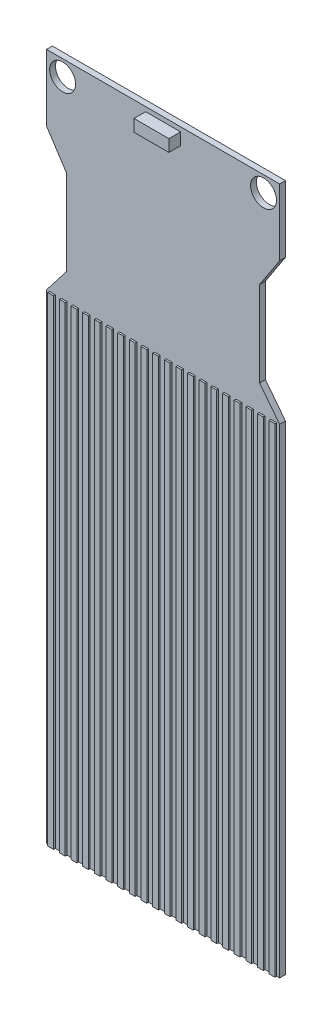
from build123d import *

# Parameters (mm, degrees)
SKETCH2_R           = 1.112004448
BOSS_EXTRUDE1_DEPTH = 0.5
SKETCH3_W           = 0.5
SKETCH3_H           = 41.135021261
BOSS_EXTRUDE2_DEPTH = 0.15
SKETCH4_W           = 1.5
SKETCH4_H           = 1.027696227
BOSS_EXTRUDE3_DEPTH = 1


with BuildPart() as part:
    # Sketch2 → Boss-Extrude1 (new body)
    with BuildSketch(Plane.XY):
        Polygon((-10, 13.571131009), (10, 13.571131009), (10, 54.708363732), (8.281546087, 56.925194639), (8.281546087, 64.240363418), (10, 66.862498938), (10, 72.571131009), (-10, 72.571131009), (-10, 66.862498938), (-8.281546087, 64.240363418), (-8.281546087, 56.925194639), (-10, 54.708363732), align=None)
        with Locations((8.618613348, 71.214744162)):
            Circle(SKETCH2_R, mode=Mode.SUBTRACT)
        with Locations((-8.618613348, 71.214744162)):
            Circle(SKETCH2_R, mode=Mode.SUBTRACT)
    extrude(amount=BOSS_EXTRUDE1_DEPTH)

    # Sketch3 → Boss-Extrude2 (add)
    with BuildSketch(Plane.XY.offset(0.5)):
        with Locations((-9.5, 34.13864164)):
            Rectangle(SKETCH3_W, SKETCH3_H)
        with Locations((-8.5, 34.13864164)):
            Rectangle(SKETCH3_W, SKETCH3_H)
        with Locations((-7.5, 34.13864164)):
            Rectangle(SKETCH3_W, SKETCH3_H)
        with Locations((-6.5, 34.13864164)):
            Rectangle(SKETCH3_W, SKETCH3_H)
        with Locations((-5.5, 34.13864164)):
            Rectangle(SKETCH3_W, SKETCH3_H)
        with Locations((-4.5, 34.13864164)):
            Rectangle(SKETCH3_W, SKETCH3_H)
        with Locations((-3.5, 34.13864164)):
            Rectangle(SKETCH3_W, SKETCH3_H)
        with Locations((-2.5, 34.13864164)):
            Rectangle(SKETCH3_W, SKETCH3_H)
        with Locations((-1.5, 34.13864164)):
            Rectangle(SKETCH3_W, SKETCH3_H)
        with Locations((-0.5, 34.13864164)):
            Rectangle(SKETCH3_W, SKETCH3_H)
        with Locations((0.5, 34.13864164)):
            Rectangle(SKETCH3_W, SKETCH3_H)
        with Locations((1.5, 34.13864164)):
            Rectangle(SKETCH3_W, SKETCH3_H)
        with Locations((2.5, 34.13864164)):
            Rectangle(SKETCH3_W, SKETCH3_H)
        with Locations((3.5, 34.13864164)):
            Rectangle(SKETCH3_W, SKETCH3_H)
        with Locations((4.5, 34.13864164)):
            Rectangle(SKETCH3_W, SKETCH3_H)
        with Locations((5.5, 34.13864164)):
            Rectangle(SKETCH3_W, SKETCH3_H)
        with Locations((6.5, 34.13864164)):
            Rectangle(SKETCH3_W, SKETCH3_H)
        with Locations((7.5, 34.13864164)):
            Rectangle(SKETCH3_W, SKETCH3_H)
        with Locations((8.5, 34.13864164)):
            Rectangle(SKETCH3_W, SKETCH3_H)
        with Locations((9.5, 34.13864164)):
            Rectangle(SKETCH3_W, SKETCH3_H)
    extrude(amount=BOSS_EXTRUDE2_DEPTH)

    # Sketch4 → Boss-Extrude3 (add)
    with BuildSketch(Plane.XY.offset(0.5)):
        with Locations((-0.75, 71.676816486)):
            Rectangle(SKETCH4_W, SKETCH4_H)
        with Locations((0.75, 71.676816486)):
            Rectangle(SKETCH4_W, SKETCH4_H)
    extrude(amount=BOSS_EXTRUDE3_DEPTH)


solid = part.part
